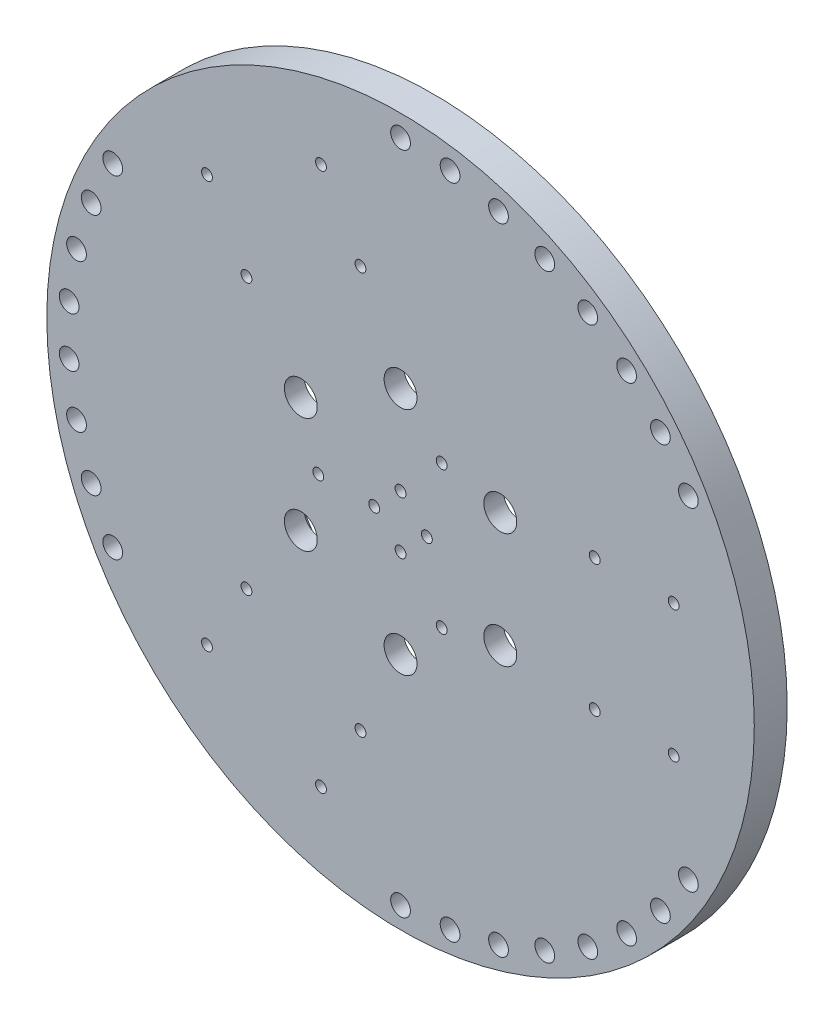
from build123d import *

# Parameters (mm, degrees)
SKETCH1_R                  = 107.5
SKETCH1_R_2                = 94
BOSS_EXTRUDE1_DEPTH        = 10
F_10_0_10_DIAMETER_HOLE1_D = 10
F_6_0_6_DIAMETER_HOLE1_D   = 6
M4_TAPPED_HOLE2_D          = 3.3
SKETCH15_R                 = 45
CUT_EXTRUDE1_DEPTH         = 4
SKETCH16_R                 = 15
CUT_EXTRUDE2_DEPTH         = 2


with BuildPart() as part:
    # Sketch1 → Boss-Extrude1 (new body)
    with BuildSketch(Plane.XY):
        Circle(SKETCH1_R)
        Circle(SKETCH1_R_2, mode=Mode.SUBTRACT)
        Circle(SKETCH1_R_2)
    extrude(amount=BOSS_EXTRUDE1_DEPTH)

    # Ø10.0 (10) Diameter Hole1 (through all)
    with Locations(Plane.XY.offset(10)):
        with Locations((-30.310889132, 17.5), (-30.310889132, -17.5), (0, -35), (30.310889132, -17.5), (30.310889132, 17.5), (0, 35)):
            Hole(F_10_0_10_DIAMETER_HOLE1_D / 2)

    # Ø6.0 (6) Diameter Hole1 (through all)
    with Locations(Plane.XY.offset(10)):
        with Locations((-87.468565782, -50.5), (-94.018248613, -36.899443461), (-98.46771913, -22.47461433), (-100.717583515, -7.547739452), (-100.717583515, 7.547739452), (-98.46771913, 22.47461433), (-94.018248613, 36.899443461), (-87.468565782, 50.5), (0, 101), (15.053268884, 99.871913449), (29.770272616, 96.512853384), (43.822257651, 90.997855658), (56.895325864, 83.450116206), (68.697446515, 74.038239055), (78.964979729, 62.972469988), (87.468565782, 50.5), (87.468565782, -50.5), (78.964979729, -62.972469988), (68.697446515, -74.038239055), (56.895325864, -83.450116206), (43.822257651, -90.997855658), (29.770272616, -96.512853384), (15.053268884, -99.871913449), (0, -101)):
            Hole(F_6_0_6_DIAMETER_HOLE1_D / 2)

    # M4 Tapped Hole2 (through all)
    with Locations(Plane.XY.offset(10)):
        with Locations((-58.820508076, 61.880108514), (-24.179491924, 81.880108514), (-12.179491924, 61.095498823), (-46.820508076, 41.095498823), (12.5, 21.650635095), (-25, 0), (12.5, -21.650635095), (59, 20), (83, 20), (59, -20), (83, -20), (-12.179491924, -61.095498823), (-46.820508076, -41.095498823), (-58.820508076, -61.880108514), (-24.179491924, -81.880108514), (-8, 0), (0, 8), (8, 0), (0, -8)):
            Hole(M4_TAPPED_HOLE2_D / 2)

    # Sketch15 → Cut-Extrude1 (cut)
    with BuildSketch(Plane(origin=(0, 0, 0), x_dir=(-1, 0, 0), z_dir=(0, 0, -1))):
        Circle(SKETCH15_R)
    extrude(amount=-CUT_EXTRUDE1_DEPTH, mode=Mode.SUBTRACT)

    # Sketch16 → Cut-Extrude2 (cut)
    with BuildSketch(Plane(origin=(0, 0, 4), x_dir=(-1, 0, 0), z_dir=(0, 0, -1))):
        Circle(SKETCH16_R)
    extrude(amount=-CUT_EXTRUDE2_DEPTH, mode=Mode.SUBTRACT)


solid = part.part
